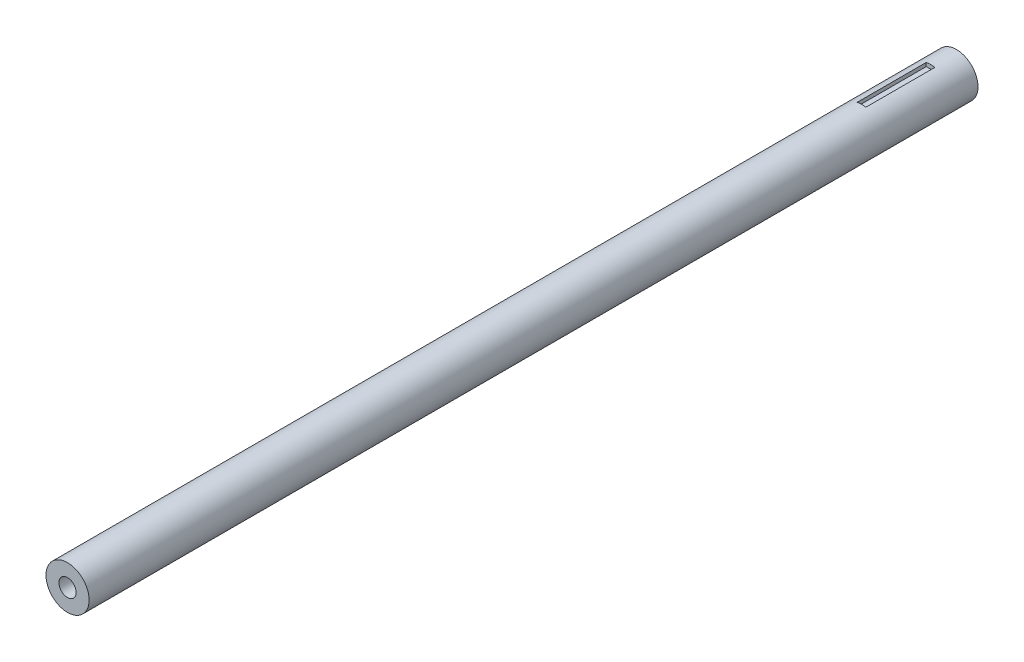
from build123d import *

# Parameters (mm, degrees)
EXTRUDE1_DEPTH      = 136.525
EXTRUDE1_DEPTH_BACK = 190.5
SKETCH1_R           = 7.9375
SKETCH2_R           = 3.175
CUT_EXTRUDE1_DEPTH  = 25.4
SKETCH3_W           = 25.4
SKETCH3_H           = 3.175
CUT_EXTRUDE2_DEPTH  = 1.5875


with BuildPart() as part:
    # Sketch1 → Extrude1 (new, two sides: drawn at the far end of the back side and taken through both)
    with BuildSketch(Plane.XY.offset(-EXTRUDE1_DEPTH_BACK)):
        Circle(SKETCH1_R)
    extrude(amount=EXTRUDE1_DEPTH + EXTRUDE1_DEPTH_BACK)

    # Sketch2 → Cut-Extrude1 (cut)
    with BuildSketch(Plane.XY.offset(136.525)):
        Circle(SKETCH2_R)
    extrude(amount=-CUT_EXTRUDE1_DEPTH, mode=Mode.SUBTRACT)

    # Sketch3 → Cut-Extrude2 (cut, symmetric)
    with BuildSketch(Plane(origin=(0, 0, 0), x_dir=(0, 0, -1), z_dir=(1, 0, 0))):
        with Locations((168.275, 8.0264)):
            Rectangle(SKETCH3_W, SKETCH3_H)
    extrude(amount=CUT_EXTRUDE2_DEPTH, both=True, mode=Mode.SUBTRACT)


solid = part.part
